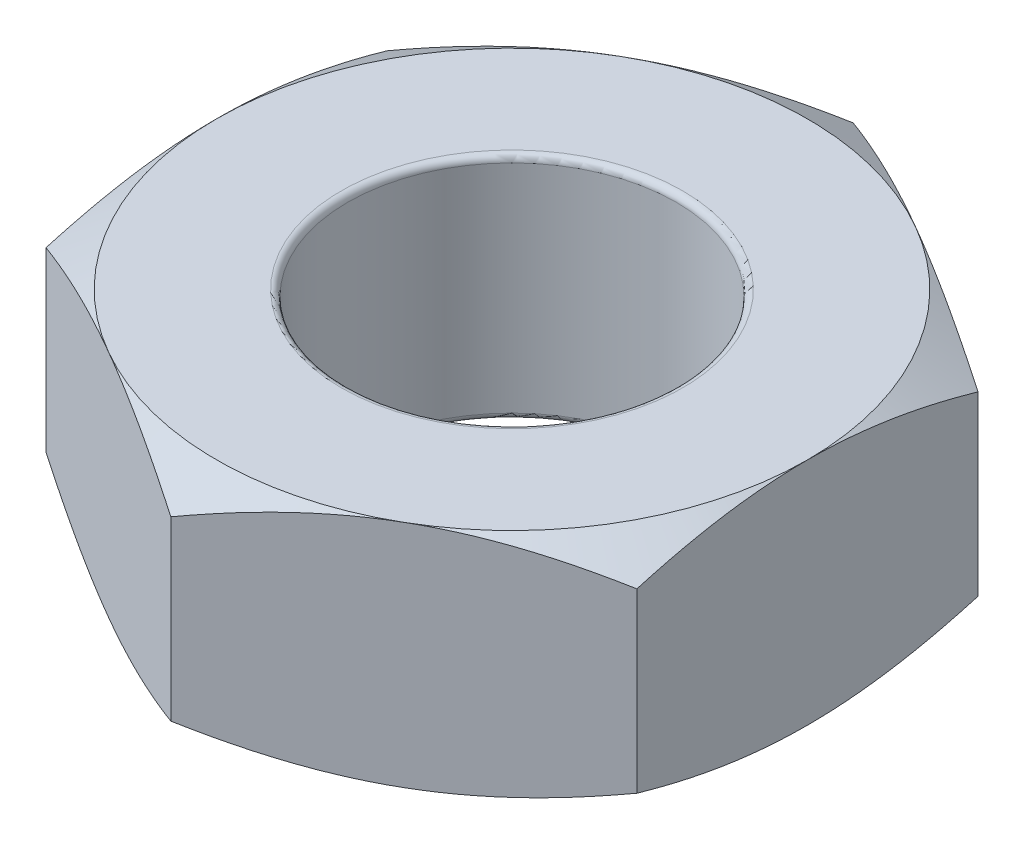
from build123d import *

# Parameters (mm, degrees)
SKETCH2_R           = 1.25
BOSS_EXTRUDE1_DEPTH = 1.75
SKETCH3_OUTSIDE_W   = 14.846
SKETCH3_OUTSIDE_H   = 15.542
SKETCH3_OUTSIDE_R   = 2.25
CUT_EXTRUDE1_DEPTH  = 2
CUT_EXTRUDE1_TAPER  = 60
SKETCH4_OUTSIDE_W   = 14.846
SKETCH4_OUTSIDE_H   = 15.542
SKETCH4_OUTSIDE_R   = 2.25
CUT_EXTRUDE2_DEPTH  = 2
CUT_EXTRUDE2_TAPER  = 60
FILLET1_R           = 0.05


with BuildPart() as part:
    # Sketch2 → Boss-Extrude1 (new body)
    with BuildSketch(Plane(origin=(0, 0, 0), x_dir=(1, 0, 0), z_dir=(0, 1, 0))):
        Polygon((2.25, -1.299038106), (2.25, 1.299038106), (0, 2.598076211), (-2.25, 1.299038106), (-2.25, -1.299038106), (0, -2.598076211), align=None)
        Circle(SKETCH2_R, mode=Mode.SUBTRACT)
    extrude(amount=BOSS_EXTRUDE1_DEPTH)

    # Sketch3 outside → Cut-Extrude1 (cut)
    with BuildSketch(Plane(origin=(0, 1.75, 0), x_dir=(1, 0, 0), z_dir=(0, 1, 0))):
        Rectangle(SKETCH3_OUTSIDE_W, SKETCH3_OUTSIDE_H)
        Circle(SKETCH3_OUTSIDE_R, mode=Mode.SUBTRACT)
    extrude(amount=-CUT_EXTRUDE1_DEPTH, taper=CUT_EXTRUDE1_TAPER, mode=Mode.SUBTRACT)

    # Sketch4 outside → Cut-Extrude2 (cut)
    with BuildSketch(Plane.XZ):
        Rectangle(SKETCH4_OUTSIDE_W, SKETCH4_OUTSIDE_H)
        Circle(SKETCH4_OUTSIDE_R, mode=Mode.SUBTRACT)
    extrude(amount=-CUT_EXTRUDE2_DEPTH, taper=CUT_EXTRUDE2_TAPER, mode=Mode.SUBTRACT)

    # Fillet1
    fillet1_edges = [part.edges().sort_by_distance(p)[0] for p in [
        (-1.25, 0, 0),
        (-1.25, 1.75, 0),
    ]]
    fillet(fillet1_edges, radius=FILLET1_R)


solid = part.part
